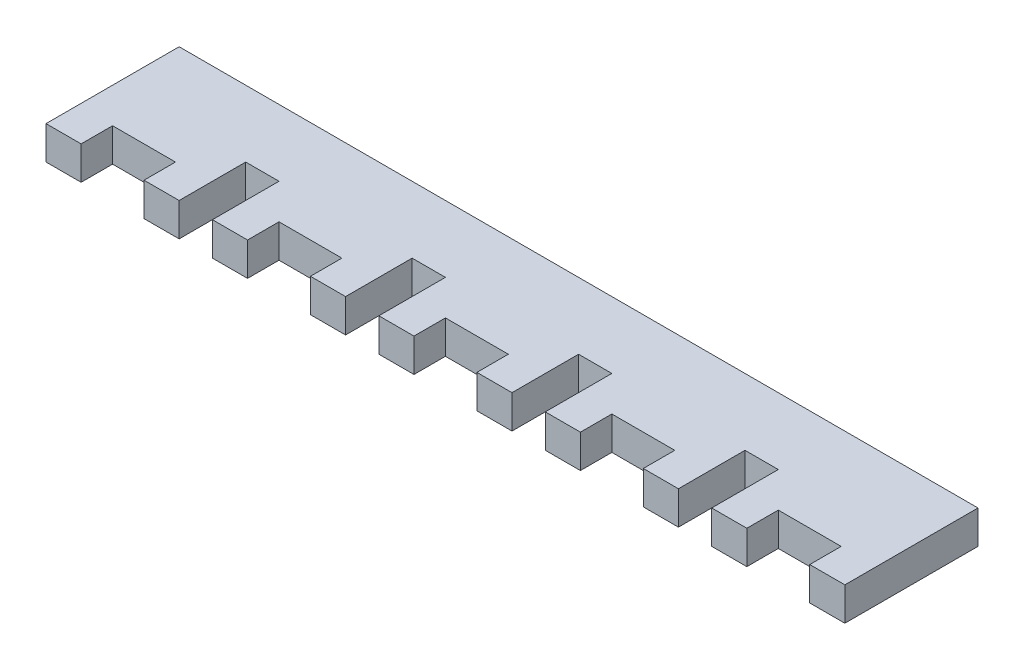
from build123d import *

# Parameters (mm, degrees)
SKETCH1_W           = 76.2
SKETCH1_H           = 12.7
BOSS_EXTRUDE1_DEPTH = 3.175
SKETCH4_W           = 3.175
SKETCH4_H           = 6.35
CUT_EXTRUDE1_DEPTH  = 4.175
LPATTERN1_COUNT     = 4
LPATTERN1_PITCH     = 15.875
CUT_EXTRUDE2_DEPTH  = 4.175
LPATTERN2_COUNT     = 5
LPATTERN2_PITCH     = 15.875


with BuildPart() as part:
    # Sketch1 → Boss-Extrude1 (new body)
    with BuildSketch(Plane(origin=(0, 0, 0), x_dir=(1, 0, 0), z_dir=(0, 1, 0))):
        with Locations((38.1, -6.35)):
            Rectangle(SKETCH1_W, SKETCH1_H)
    extrude(amount=BOSS_EXTRUDE1_DEPTH)

    # Sketch4 → Cut-Extrude1 (cut, through all)
    with BuildSketch(Plane(origin=(0, 3.175, 0), x_dir=(1, 0, 0), z_dir=(0, 1, 0))):
        with Locations((14.2875, -9.525)):
            Rectangle(SKETCH4_W, SKETCH4_H)
    cut_extrude1 = extrude(amount=-CUT_EXTRUDE1_DEPTH, mode=Mode.SUBTRACT)

    # LPattern1: Cut-Extrude1 ×4
    with Locations(*[(i * LPATTERN1_PITCH, 0, 0) for i in range(1, LPATTERN1_COUNT)]):
        add(cut_extrude1, mode=Mode.SUBTRACT)

    # Sketch5 → Cut-Extrude2 (cut, through all)
    with BuildSketch(Plane(origin=(0, 3.175, 0), x_dir=(1, 0, 0), z_dir=(0, 1, 0))):
        Polygon((6.35, -9.7), (9.35, -9.7), (9.35, -12.7), (3.35, -12.7), (3.35, -9.7), align=None)
    cut_extrude2 = extrude(amount=-CUT_EXTRUDE2_DEPTH, mode=Mode.SUBTRACT)

    # LPattern2: Cut-Extrude2 ×5
    with Locations(*[(i * LPATTERN2_PITCH, 0, 0) for i in range(1, LPATTERN2_COUNT)]):
        add(cut_extrude2, mode=Mode.SUBTRACT)


solid = part.part
